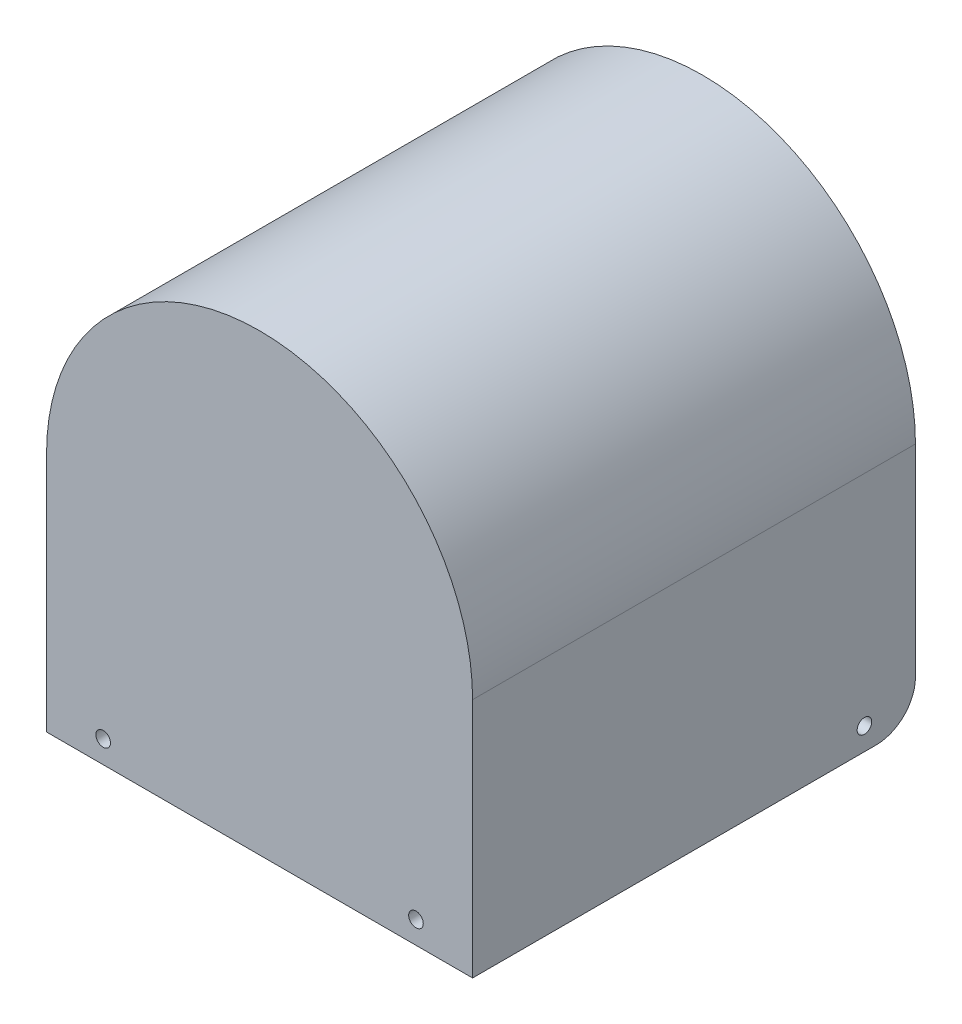
from build123d import *

# Parameters (mm, degrees)
BOSS_EXTRUDE1_DEPTH                  = 79
SKETCH2_W                            = 72
SKETCH2_H                            = 2
BOSS_EXTRUDE2_DEPTH                  = 43
BOSS_EXTRUDE2_DIRECTION_2_REACH      = 99.642
BOSS_EXTRUDE2_DIRECTION_2_END_RADIUS = 36
SKETCH3_R                            = 1.3
CUT_EXTRUDE1_DEPTH                   = 10
SKETCH4_R                            = 1.3
CUT_EXTRUDE2_DEPTH                   = 118.753980824
FILLET1_R                            = 7


with BuildPart() as part:
    # Sketch1 → Boss-Extrude1 (new body)
    with BuildSketch(Plane.XY):
        with BuildLine():
            Line((-36, 0), (-36, -43))
            Line((-36, -43), (-38, -43))
            Line((-38, -43), (-38, 0))
            ThreePointArc((-38, 0), (0, 38), (38, 0))
            Line((38, 0), (38, -43))
            Line((38, -43), (36, -43))
            Line((36, -43), (36, 0))
            ThreePointArc((36, 0), (0, 36), (-36, 0))
        make_face()
    extrude(amount=BOSS_EXTRUDE1_DEPTH)

    # Sketch2 → Boss-Extrude2 (add)
    with BuildSketch(Plane(origin=(0, 0, 0), x_dir=(1, 0, 0), z_dir=(0, 1, 0))):
        with Locations((0, -78)):
            Rectangle(SKETCH2_W, SKETCH2_H)
    extrude(amount=-BOSS_EXTRUDE2_DEPTH)

    # Boss-Extrude2 direction 2: up to this cylinder (the profile starts inside it)
    boss_extrude2_direction_2_end = Plane(origin=(0, 0, 78), z_dir=(0, 0, -1)) * Cylinder(BOSS_EXTRUDE2_DIRECTION_2_END_RADIUS, 272.284, mode=Mode.PRIVATE)
    # Sketch2 → Boss-Extrude2 direction 2 (add, up to the surface)
    with BuildSketch(Plane(origin=(0, 0, 0), x_dir=(1, 0, 0), z_dir=(0, 1, 0)), mode=Mode.PRIVATE) as boss_extrude2_direction_2_sk1:
        with Locations((0, -78)):
            Rectangle(SKETCH2_W, SKETCH2_H)
    boss_extrude2_direction_2_tool1 = extrude(boss_extrude2_direction_2_sk1.sketch, amount=BOSS_EXTRUDE2_DIRECTION_2_REACH, mode=Mode.PRIVATE) & boss_extrude2_direction_2_end
    add(boss_extrude2_direction_2_tool1.solids().sort_by_distance((0, 0, 78))[0])

    # Sketch3 → Cut-Extrude1 (cut)
    with BuildSketch(Plane.XY.offset(79)):
        with Locations((-27.9, -39)):
            Circle(SKETCH3_R)
        with Locations((27.9, -39)):
            Circle(SKETCH3_R)
    extrude(amount=-CUT_EXTRUDE1_DEPTH, mode=Mode.SUBTRACT)

    # Sketch4 → Cut-Extrude2 (cut, through all)
    with BuildSketch(Plane(origin=(38, 0, 0), x_dir=(0, 0, -1), z_dir=(1, 0, 0))):
        with Locations(Location((-9.1, -39, 0), (0, 0, 90))):
            Circle(SKETCH4_R)
    extrude(amount=-CUT_EXTRUDE2_DEPTH, mode=Mode.SUBTRACT)

    # Fillet1
    fillet1_edges = [part.edges().sort_by_distance(p)[0] for p in [
        (-37, -43, 0),
        (37, -43, 0),
    ]]
    fillet(fillet1_edges, radius=FILLET1_R)


solid = part.part
